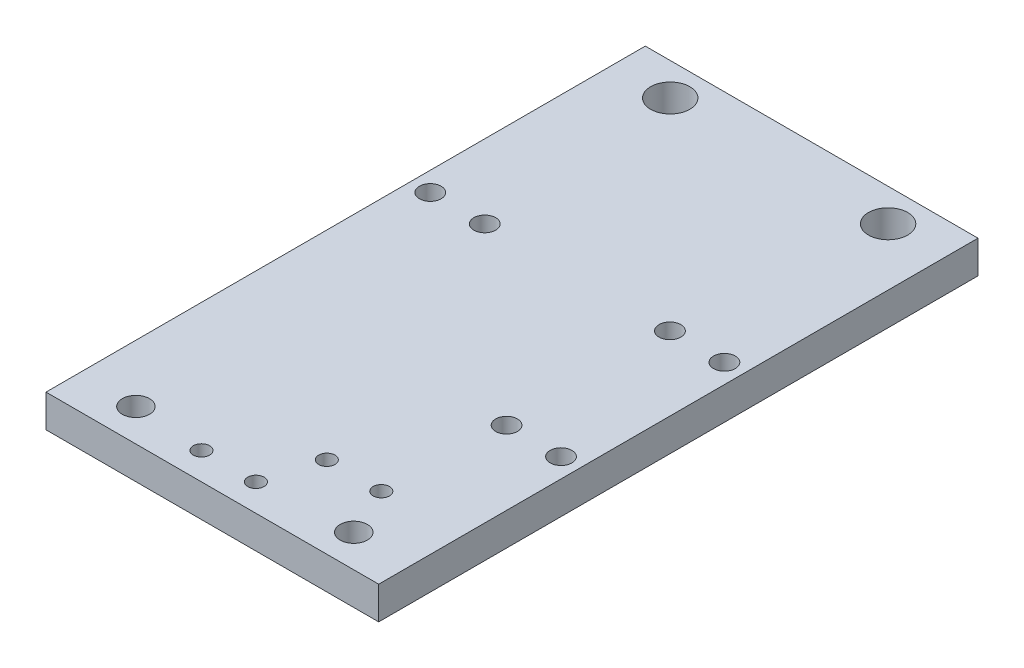
from build123d import *

# Parameters (mm, degrees)
BOSS_EXTRUDE1_DEPTH = 6
SKETCH1_3_R         = 3.6
SKETCH1_3_R_2       = 2.5
SKETCH1_3_R_3       = 2
SKETCH1_3_R_4       = 1.5
CUT_EXTRUDE1_DEPTH  = 6


with BuildPart() as part:
    # Sketch1 → Boss-Extrude1 (new body)
    with BuildSketch(Plane(origin=(0, 0, 0), x_dir=(1, 0, 0), z_dir=(0, 1, 0))):
        Polygon((-30.541760722, -55.01618123), (30.541760722, -55.01618123), (30.541760722, 55.01618123), (-30.541760722, 55.01618123), (-30.541760722, 29.2), align=None)
    extrude(amount=BOSS_EXTRUDE1_DEPTH)

    # Sketch1_3 → Cut-Extrude1 (cut)
    with BuildSketch(Plane(origin=(0, 0, 0), x_dir=(1, 0, 0), z_dir=(0, 1, 0))):
        with Locations((-20, 49.05)):
            Circle(SKETCH1_3_R)
        with Locations((20, 49.05)):
            Circle(SKETCH1_3_R)
        with Locations((-20, -49.05)):
            Circle(SKETCH1_3_R_2)
        with Locations((20, -49.05)):
            Circle(SKETCH1_3_R_2)
        with Locations((17, 12)):
            Circle(SKETCH1_3_R_3)
        with Locations((27, 12)):
            Circle(SKETCH1_3_R_3)
        with Locations((27, -18)):
            Circle(SKETCH1_3_R_3)
        with Locations((17, -18)):
            Circle(SKETCH1_3_R_3)
        with Locations((-7, -50.01618123)):
            Circle(SKETCH1_3_R_4)
        with Locations((3, -50.01618123)):
            Circle(SKETCH1_3_R_4)
        with Locations((-27, 12)):
            Circle(SKETCH1_3_R_3)
        with Locations((-17, 12)):
            Circle(SKETCH1_3_R_3)
        with Locations((6, -40)):
            Circle(SKETCH1_3_R_4)
        with Locations((16, -40)):
            Circle(SKETCH1_3_R_4)
    extrude(amount=CUT_EXTRUDE1_DEPTH, mode=Mode.SUBTRACT)


solid = part.part
